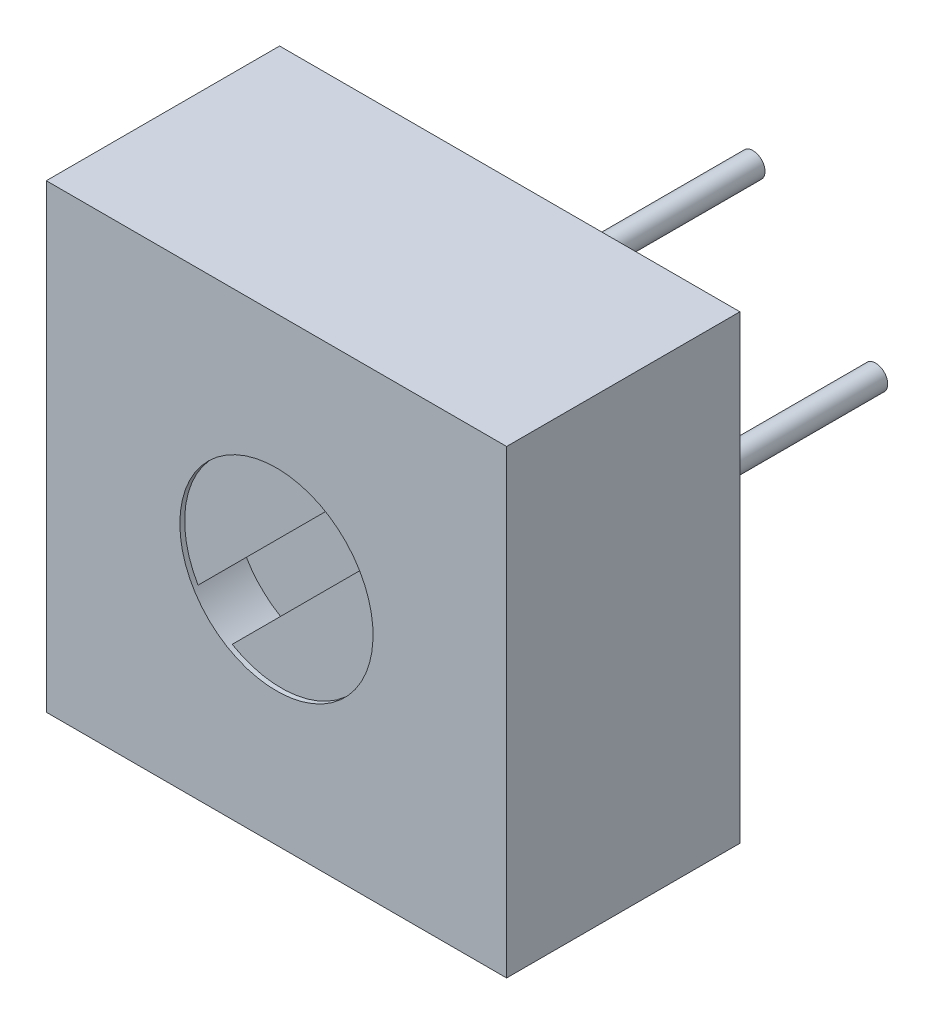
from build123d import *

# Parameters (mm, degrees)
SKETCH1_W           = 9.53
SKETCH1_H           = 9.53
BASIC_SHAPE_DEPTH   = 4.83
SKETCH2_R           = 0.25
PINS_DEPTH          = 5
SKETCH3_R           = 2
ADJUSTER_DEPTH      = 0.1
ADJUSTER_SLOT_DEPTH = 1


with BuildPart() as part:
    # Sketch1 → Basic Shape (new body)
    with BuildSketch(Plane(origin=(0, 0, 0), x_dir=(1, 0, 0), z_dir=(0, 0, -1))):
        with Locations((4.765, 4.765)):
            Rectangle(SKETCH1_W, SKETCH1_H)
    extrude(amount=BASIC_SHAPE_DEPTH)

    # Sketch2 → Pins (add)
    with BuildSketch(Plane.XY.offset(-4.83)):
        with Locations((4.8, -7.305)):
            Circle(SKETCH2_R)
        with Locations((4.8, -2.225)):
            Circle(SKETCH2_R)
        with Locations((7.34, -4.765)):
            Circle(SKETCH2_R)
    extrude(amount=-PINS_DEPTH)

    # Sketch3 → Adjuster (cut)
    with BuildSketch(Plane(origin=(0, 0, 0), x_dir=(-1, 0, 0), z_dir=(0, 0, -1))):
        with Locations((-4.765, -4.765)):
            Circle(SKETCH3_R)
    extrude(amount=ADJUSTER_DEPTH, mode=Mode.SUBTRACT)

    # Sketch4 → Adjuster Slot (cut)
    with BuildSketch(Plane(origin=(0, 0, -0.1), x_dir=(-1, 0, 0), z_dir=(0, 0, 1))):
        with BuildLine():
            Line((-6.487859784, 3.749246997), (-3.749246997, 6.487859784))
            ThreePointArc((-3.749246997, 6.487859784), (-3.350786438, 6.179213562), (-3.042140216, 5.780753003))
            Line((-3.042140216, 5.780753003), (-5.780753003, 3.042140216))
            ThreePointArc((-5.780753003, 3.042140216), (-6.179213562, 3.350786438), (-6.487859784, 3.749246997))
        make_face()
    extrude(amount=-ADJUSTER_SLOT_DEPTH, mode=Mode.SUBTRACT)


solid = part.part
